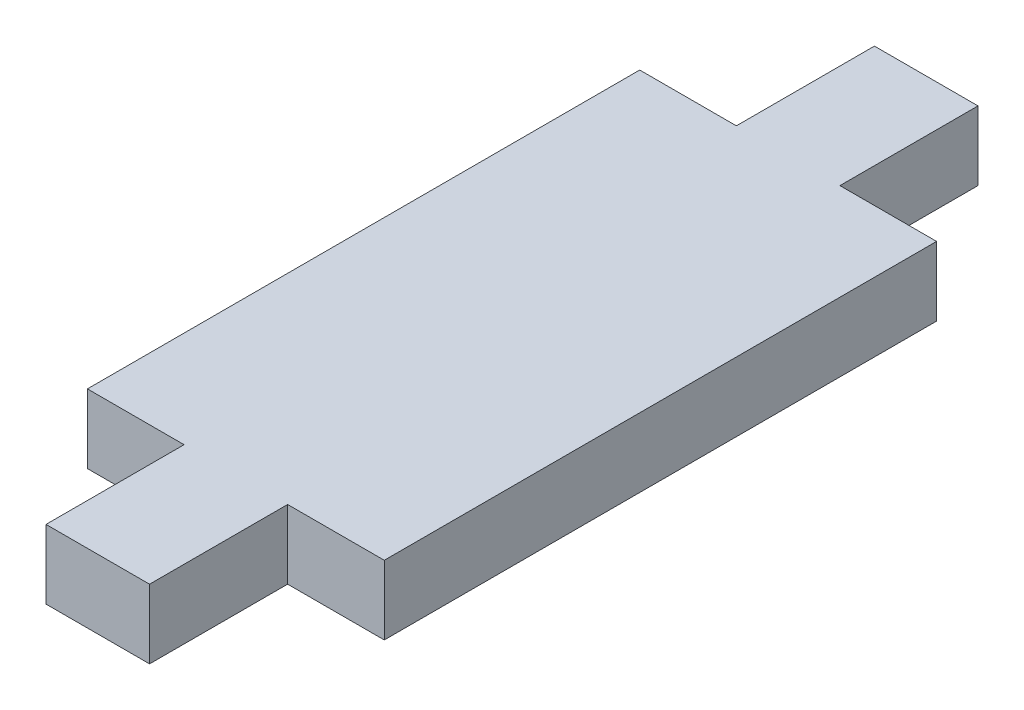
from build123d import *

# Parameters (mm, degrees)
BOSS_EXTRUDE1_DEPTH = 5


with BuildPart() as part:
    # Sketch1 → Boss-Extrude1 (new body)
    with BuildSketch(Plane(origin=(0, 0, 0), x_dir=(1, 0, 0), z_dir=(0, 1, 0))):
        Polygon((-10.75, 20), (-3.75, 20), (-3.75, 30), (3.75, 30), (3.75, 20), (10.75, 20), (10.75, -20), (3.75, -20), (3.75, -30), (-3.75, -30), (-3.75, -20), (-10.75, -20), align=None)
    extrude(amount=BOSS_EXTRUDE1_DEPTH)


solid = part.part
